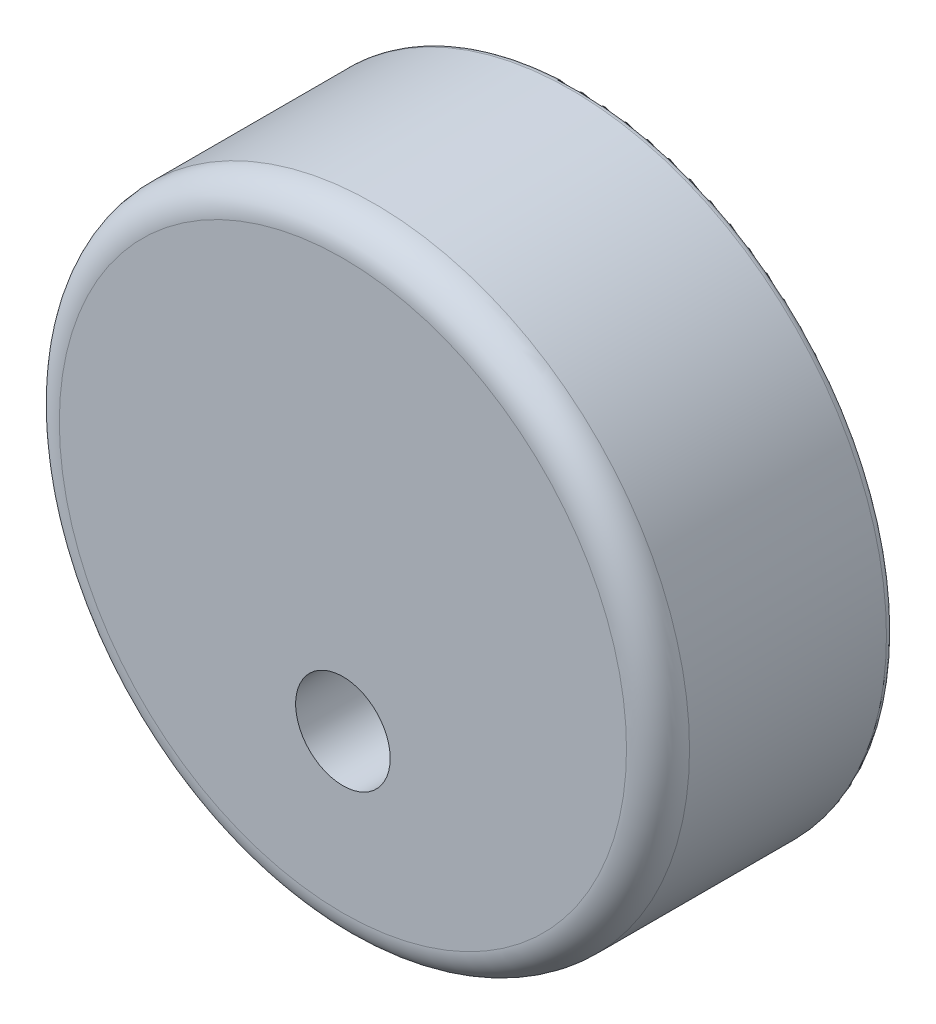
from build123d import *

# Parameters (mm, degrees)
SKETCH1_R           = 20
BOSS_EXTRUDE1_DEPTH = 15
SKETCH2_R           = 3
CUT_EXTRUDE1_DEPTH  = 16
FILLET1_R           = 2
FILLET2_R           = 0.5


with BuildPart() as part:
    # Sketch1 → Boss-Extrude1 (new body)
    with BuildSketch(Plane.XY):
        Circle(SKETCH1_R)
    extrude(amount=BOSS_EXTRUDE1_DEPTH)

    # Sketch2 → Cut-Extrude1 (cut, through all)
    with BuildSketch(Plane.XY.offset(15)):
        with Locations((0, -8)):
            Circle(SKETCH2_R)
    extrude(amount=-CUT_EXTRUDE1_DEPTH, mode=Mode.SUBTRACT)

    # Fillet1
    fillet1_edges = [part.edges().sort_by_distance(p)[0] for p in [
        (-20, 0, 15),
    ]]
    fillet(fillet1_edges, radius=FILLET1_R)

    # Fillet2
    fillet2_edges = [part.edges().sort_by_distance(p)[0] for p in [
        (-20, 0, 0),
    ]]
    fillet(fillet2_edges, radius=FILLET2_R)


solid = part.part
